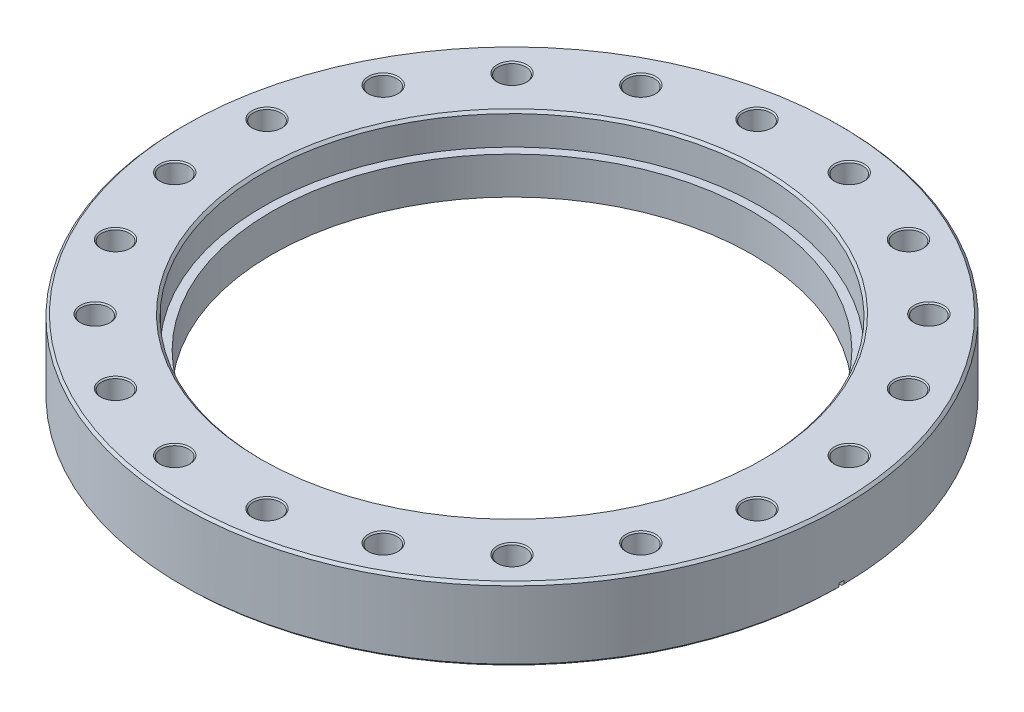
from build123d import *

# Parameters (mm, degrees)
SKETCH1_R                    = 101.219
SKETCH1_R_2                  = 73.8124
BOSS_EXTRUDE1_DEPTH          = 22.352
SKETCH2_R                    = 76.454
CUT_EXTRUDE1_DEPTH           = 9.652
CHAMFER1_SIZE                = 0.762
SKETCH3_R                    = 4.2164
CUT_EXTRUDE2_DEPTH           = 23.352
CHAMFER2_SIZE                = 0.381
CIRPATTERN1_COUNT            = 20
CHAMFER2_OF_CIRPATTERN1_SIZE = 0.381
CUT_EXTRUDE3_DEPTH           = 0.79375


with BuildPart() as part:
    # Sketch1 → Boss-Extrude1 (new body)
    with BuildSketch(Plane(origin=(0, 0, 0), x_dir=(1, 0, 0), z_dir=(0, 1, 0))):
        Circle(SKETCH1_R)
        Circle(SKETCH1_R_2, mode=Mode.SUBTRACT)
    extrude(amount=BOSS_EXTRUDE1_DEPTH)

    # Sketch2 → Cut-Extrude1 (cut)
    with BuildSketch(Plane(origin=(0, 22.352, 0), x_dir=(-1, 0, 0), z_dir=(0, -1, 0))):
        Circle(SKETCH2_R)
    extrude(amount=CUT_EXTRUDE1_DEPTH, mode=Mode.SUBTRACT)

    # Chamfer1
    chamfer1_edges = [part.edges().sort_by_distance(p)[0] for p in [
        (76.454, 22.352, 0),
        (-101.219, 0, 0),
        (-101.219, 22.352, 0),
    ]]
    chamfer(chamfer1_edges, length=CHAMFER1_SIZE)

    # Sketch4 → Cut-Revolve1 (revolve, cut)
    with BuildSketch(Plane.XY):
        Polygon((-85.725, 0), (-85.725, 1.6256), (-83.058, 0.6604), (-83.058, 1.27), (0, 1.27), (0, 0), align=None)
    revolve(axis=Axis((0, 22.352, 0), (0, -1, 0)), mode=Mode.SUBTRACT)

    # Sketch3 → Cut-Extrude2 (cut, through all)
    with BuildSketch(Plane(origin=(0, 22.352, 0), x_dir=(1, 0, 0), z_dir=(0, 1, 0))):
        with Locations((-14.161323808, 89.411079645)):
            Circle(SKETCH3_R)
    cut_extrude2 = extrude(amount=-CUT_EXTRUDE2_DEPTH, mode=Mode.SUBTRACT)

    # Chamfer2
    chamfer2_edges = [part.edges().sort_by_distance(p)[0] for p in [
        (-18.377723808, 0, -89.411079645),
        (-18.377723808, 22.352, -89.411079645),
    ]]
    chamfer(chamfer2_edges, length=CHAMFER2_SIZE)

    # CirPattern1: Cut-Extrude2 ×20 about axis
    cirpattern1_axis = Axis((0, 0, 0), (0, 1, 0))
    for i in range(1, CIRPATTERN1_COUNT):
        add(cut_extrude2.rotate(cirpattern1_axis, i * 360 / CIRPATTERN1_COUNT), mode=Mode.SUBTRACT)

    # Chamfer2 of CirPattern1
    chamfer2_of_cirpattern1_edges = [part.edges().sort_by_distance(p)[0] for p in [
        (-45.107797079, 0, -79.355960951),
        (-45.107797079, 22.352, -79.355960951),
        (-67.422404886, 0, -61.532927893),
        (-67.422404886, 22.352, -61.532927893),
        (-83.137237944, 0, -37.686623128),
        (-83.137237944, 22.352, -37.686623128),
        (-90.7140189, 0, -10.151289113),
        (-90.7140189, 22.352, -10.151289113),
        (-89.411079645, 0, 18.377723808),
        (-89.411079645, 22.352, 18.377723808),
        (-79.355960951, 0, 45.107797079),
        (-79.355960951, 22.352, 45.107797079),
        (-61.532927893, 0, 67.422404886),
        (-61.532927893, 22.352, 67.422404886),
        (-37.686623128, 0, 83.137237944),
        (-37.686623128, 22.352, 83.137237944),
        (-10.151289113, 0, 90.7140189),
        (-10.151289113, 22.352, 90.7140189),
        (18.377723808, 0, 89.411079645),
        (18.377723808, 22.352, 89.411079645),
        (45.107797079, 0, 79.355960951),
        (45.107797079, 22.352, 79.355960951),
        (67.422404886, 0, 61.532927893),
        (67.422404886, 22.352, 61.532927893),
        (83.137237944, 0, 37.686623128),
        (83.137237944, 22.352, 37.686623128),
        (90.7140189, 0, 10.151289113),
        (90.7140189, 22.352, 10.151289113),
        (89.411079645, 0, -18.377723808),
        (89.411079645, 22.352, -18.377723808),
        (79.355960951, 0, -45.107797079),
        (79.355960951, 22.352, -45.107797079),
        (61.532927893, 0, -67.422404886),
        (61.532927893, 22.352, -67.422404886),
        (37.686623128, 0, -83.137237944),
        (37.686623128, 22.352, -83.137237944),
        (10.151289113, 0, -90.7140189),
        (10.151289113, 22.352, -90.7140189),
    ]]
    chamfer(chamfer2_of_cirpattern1_edges, length=CHAMFER2_OF_CIRPATTERN1_SIZE)

    # Sketch5 → Cut-Extrude3 (cut, symmetric)
    with BuildSketch(Plane.XY):
        Polygon((-85.354321688, 0.946996712), (-101.219, 1.778429271), (-101.219, -3.52623374), (-85.354321688, -3.52623374), align=None)
        Polygon((85.354321688, 0.946996712), (85.354321688, -3.52623374), (101.219, -3.52623374), (101.219, 1.778429271), align=None)
    extrude(amount=CUT_EXTRUDE3_DEPTH, both=True, mode=Mode.SUBTRACT)


solid = part.part
